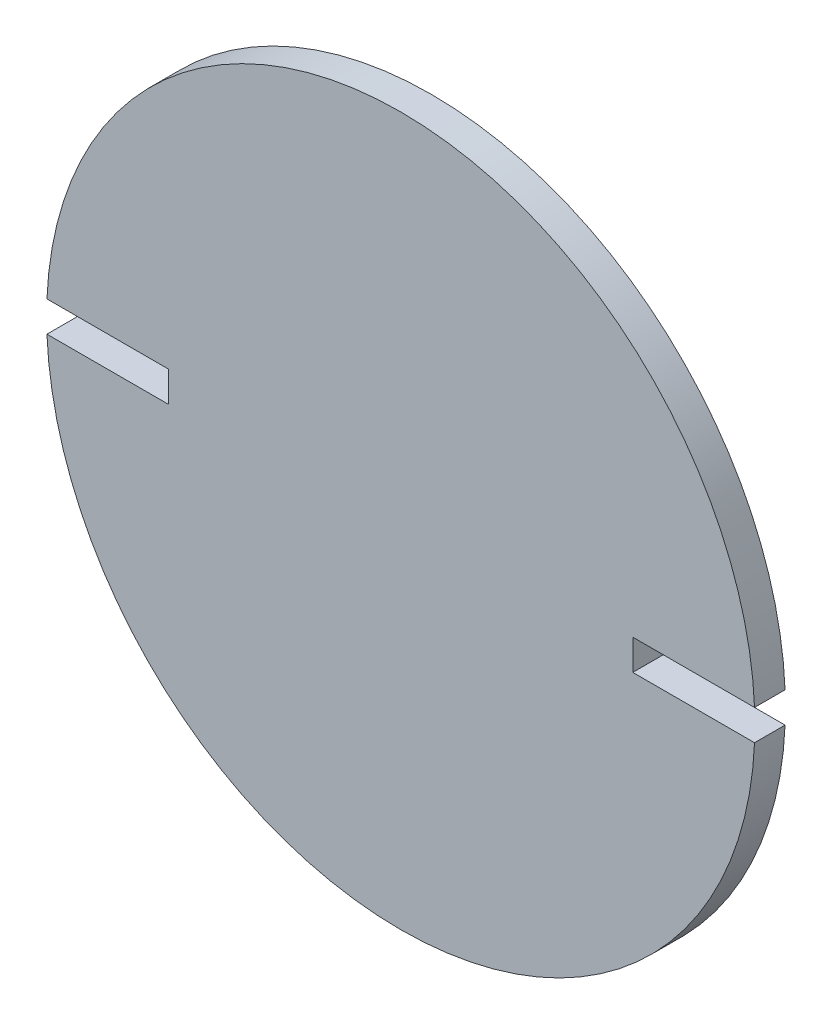
from build123d import *

# Parameters (mm, degrees)
SKETCH1_R           = 73.66
BOSS_EXTRUDE1_DEPTH = 6.35
CUT_EXTRUDE1_DEPTH  = 7.35


with BuildPart() as part:
    # Sketch1 → Boss-Extrude1 (new body)
    with BuildSketch(Plane.XY):
        Circle(SKETCH1_R)
    extrude(amount=BOSS_EXTRUDE1_DEPTH)

    # Sketch2 → Cut-Extrude1 (cut, through all)
    with BuildSketch(Plane(origin=(0, 0, 0), x_dir=(-1, 0, 0), z_dir=(0, 0, -1))):
        Polygon((-48.26, 0), (-48.26, 3.175), (-76.2, 3.175), (-76.2, -3.175), (-48.26, -3.175), align=None)
        Polygon((48.26, -3.175), (48.26, 0), (48.26, 3.175), (76.2, 3.175), (76.2, -3.175), align=None)
    extrude(amount=-CUT_EXTRUDE1_DEPTH, mode=Mode.SUBTRACT)


solid = part.part
